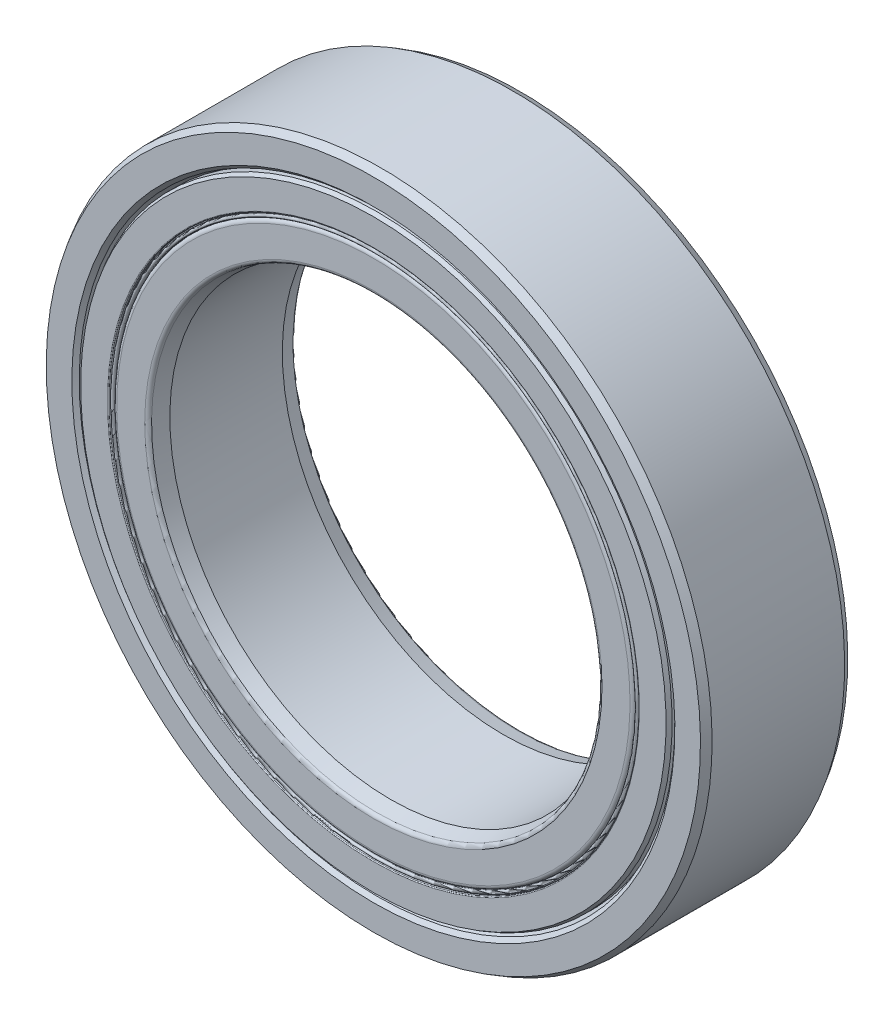
from build123d import *

# Parameters (mm, degrees)
CIRPATTERN1_COUNT = 14


with BuildPart() as part:
    # Sketch3 → Revolve1 (revolve)
    with BuildSketch(Plane(origin=(0, 0, 0), x_dir=(0, 0, -1), z_dir=(1, 0, 0))):
        with BuildLine():
            Line((-1.682987285, 8.01), (-1.9, 8.088986169))
            Line((-1.9, 8.088986169), (-2, 8.188986169))
            Line((-2, 8.188986169), (-2, 8.884529946))
            Line((-2, 8.884529946), (-1.8, 9))
            Line((-1.8, 9), (1.8, 9))
            Line((1.8, 9), (2, 8.884529946))
            Line((2, 8.884529946), (2, 8.188986169))
            Line((2, 8.188986169), (1.9, 8.088986169))
            Line((1.9, 8.088986169), (1.682987285, 8.01))
            Line((1.682987285, 8.01), (1.024402265, 8.01))
            ThreePointArc((1.024402265, 8.01), (0, 8.67), (-1.024402265, 8.01))
            Line((-1.024402265, 8.01), (-1.682987285, 8.01))
        make_face()
    revolve(axis=Axis((0, 0, 2), (0, 0, -1)))


with BuildPart() as body_2:
    # Sketch4 → Revolve2 (revolve)
    with BuildSketch(Plane(origin=(0, 0, 0), x_dir=(0, 0, -1), z_dir=(1, 0, 0))):
        with BuildLine():
            Line((-1.527565331, 6), (-1.919430666, 6.105))
            ThreePointArc((-1.919430666, 6.105), (-1.977536682, 6.143825198), (-2, 6.21))
            Line((-2, 6.21), (-2, 6.971296001))
            ThreePointArc((-2, 6.971296001), (-1.968161336, 7.048161336), (-1.891296001, 7.08))
            Line((-1.891296001, 7.08), (-1.024402265, 7.08))
            ThreePointArc((-1.024402265, 7.08), (0, 6.42), (1.024402265, 7.08))
            Line((1.024402265, 7.08), (1.891296001, 7.08))
            ThreePointArc((1.891296001, 7.08), (1.968161336, 7.048161336), (2, 6.971296001))
            Line((2, 6.971296001), (2, 6.21))
            ThreePointArc((2, 6.21), (1.977536682, 6.143825198), (1.919430666, 6.105))
            Line((1.919430666, 6.105), (1.527565331, 6))
            Line((1.527565331, 6), (-1.527565331, 6))
        make_face()
    revolve(axis=Axis((0, 0, 2), (0, 0, -1)))


with BuildPart() as body_3:
    # Sketch5 → Revolve3 (revolve)
    with BuildSketch(Plane(origin=(0, 0, 0), x_dir=(0, 0, -1), z_dir=(1, 0, 0))):
        with BuildLine():
            Line((-1.125, 7.545), (1.125, 7.545))
            ThreePointArc((1.125, 7.545), (0, 8.67), (-1.125, 7.545))
        make_face()
    revolve(axis=Axis((0, 7.545, 1.125), (0, 0, -1)))


with BuildPart() as cirpattern1_1:
    # CirPattern1: pattern copy
    add(body_3.part.rotate(Axis((0, 0, 0), (0, 0, 1)), 1 * 360 / CIRPATTERN1_COUNT))


with BuildPart() as cirpattern1_2:
    # CirPattern1: pattern copy
    add(body_3.part.rotate(Axis((0, 0, 0), (0, 0, 1)), 2 * 360 / CIRPATTERN1_COUNT))


with BuildPart() as cirpattern1_3:
    # CirPattern1: pattern copy
    add(body_3.part.rotate(Axis((0, 0, 0), (0, 0, 1)), 3 * 360 / CIRPATTERN1_COUNT))


with BuildPart() as cirpattern1_4:
    # CirPattern1: pattern copy
    add(body_3.part.rotate(Axis((0, 0, 0), (0, 0, 1)), 4 * 360 / CIRPATTERN1_COUNT))


with BuildPart() as cirpattern1_5:
    # CirPattern1: pattern copy
    add(body_3.part.rotate(Axis((0, 0, 0), (0, 0, 1)), 5 * 360 / CIRPATTERN1_COUNT))


with BuildPart() as cirpattern1_6:
    # CirPattern1: pattern copy
    add(body_3.part.rotate(Axis((0, 0, 0), (0, 0, 1)), 6 * 360 / CIRPATTERN1_COUNT))


with BuildPart() as cirpattern1_7:
    # CirPattern1: pattern copy
    add(body_3.part.rotate(Axis((0, 0, 0), (0, 0, 1)), 7 * 360 / CIRPATTERN1_COUNT))


with BuildPart() as cirpattern1_8:
    # CirPattern1: pattern copy
    add(body_3.part.rotate(Axis((0, 0, 0), (0, 0, 1)), 8 * 360 / CIRPATTERN1_COUNT))


with BuildPart() as cirpattern1_9:
    # CirPattern1: pattern copy
    add(body_3.part.rotate(Axis((0, 0, 0), (0, 0, 1)), 9 * 360 / CIRPATTERN1_COUNT))


with BuildPart() as cirpattern1_10:
    # CirPattern1: pattern copy
    add(body_3.part.rotate(Axis((0, 0, 0), (0, 0, 1)), 10 * 360 / CIRPATTERN1_COUNT))


with BuildPart() as cirpattern1_11:
    # CirPattern1: pattern copy
    add(body_3.part.rotate(Axis((0, 0, 0), (0, 0, 1)), 11 * 360 / CIRPATTERN1_COUNT))


with BuildPart() as cirpattern1_12:
    # CirPattern1: pattern copy
    add(body_3.part.rotate(Axis((0, 0, 0), (0, 0, 1)), 12 * 360 / CIRPATTERN1_COUNT))


with BuildPart() as cirpattern1_13:
    # CirPattern1: pattern copy
    add(body_3.part.rotate(Axis((0, 0, 0), (0, 0, 1)), 13 * 360 / CIRPATTERN1_COUNT))


with BuildPart() as body_17:
    # Sketch6 → Revolve4 (revolve)
    with BuildSketch(Plane(origin=(0, 0, 0), x_dir=(0, 0, -1), z_dir=(1, 0, 0))):
        with BuildLine():
            Line((-1.896076952, 8.01), (-1.125, 8.01))
            Line((-1.125, 8.01), (-1.125, 7.2))
            Line((-1.125, 7.2), (-1.976, 7.2))
            ThreePointArc((-1.976, 7.2), (-1.992970563, 7.207029437), (-2, 7.224))
            Line((-2, 7.224), (-2, 7.95))
            Line((-2, 7.95), (-1.896076952, 8.01))
        make_face()
        with BuildLine():
            Line((1.976, 7.2), (1.125, 7.2))
            Line((1.125, 7.2), (1.125, 8.01))
            Line((1.125, 8.01), (1.896076952, 8.01))
            Line((1.896076952, 8.01), (2, 7.95))
            Line((2, 7.95), (2, 7.224))
            ThreePointArc((2, 7.224), (1.992970563, 7.207029437), (1.976, 7.2))
        make_face()
    revolve(axis=Axis((0, 0, 2), (0, 0, -1)))


with BuildPart() as body_18:
    # Sketch7 → Revolve5 (revolve)
    with BuildSketch(Plane(origin=(0, 0, 0), x_dir=(0, 0, -1), z_dir=(1, 0, 0))):
        with BuildLine():
            Line((-1.125, 7.2), (-1.90262466, 7.2))
            Line((-1.90262466, 7.2), (-1.932168892, 7.194790555))
            ThreePointArc((-1.932168892, 7.194790555), (-1.942442625, 7.181401565), (-1.93, 7.17))
            Line((-1.93, 7.17), (-1.955, 7.17))
            ThreePointArc((-1.955, 7.17), (-2, 7.125), (-1.955, 7.08))
            Line((-1.955, 7.08), (-1.125, 7.08))
            Line((-1.125, 7.08), (-1.125, 7.2))
        make_face()
    revolve(axis=Axis((0, 0, 2), (0, 0, -1)))


solid = Compound([part.part, body_2.part, body_3.part, cirpattern1_1.part, cirpattern1_2.part, cirpattern1_3.part, cirpattern1_4.part, cirpattern1_5.part, cirpattern1_6.part, cirpattern1_7.part, cirpattern1_8.part, cirpattern1_9.part, cirpattern1_10.part, cirpattern1_11.part, cirpattern1_12.part, cirpattern1_13.part, body_17.part, body_18.part])
